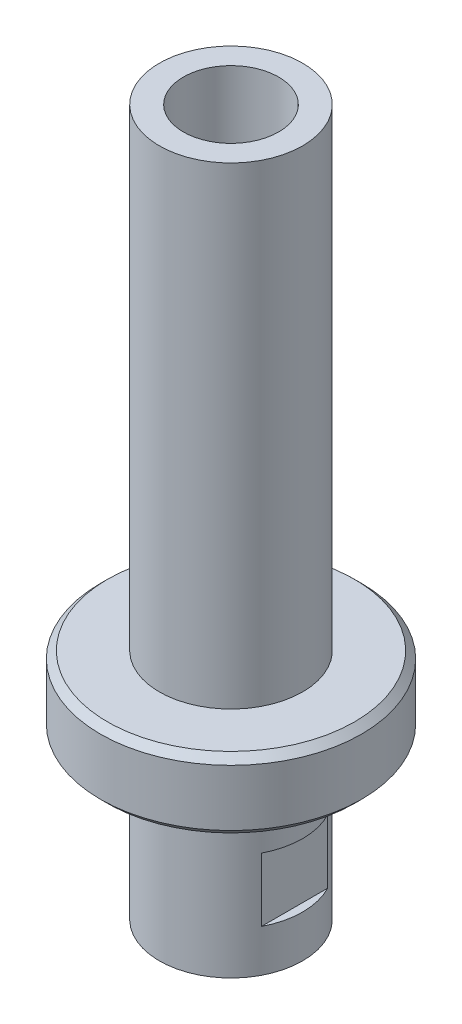
from build123d import *

# Parameters (mm, degrees)
SKETCH2_W               = 3
SKETCH2_H               = 9
CUT_EXTRUDE1_DEPTH      = 19.5
CUT_EXTRUDE1_DEPTH_BACK = 19.5
CHAMFER1_SIZE           = 1


with BuildPart() as part:
    # Sketch1 → Revolve1 (revolve)
    with BuildSketch(Plane.XY):
        Polygon((10.15, 100), (10.15, 33), (18.5, 33), (18.5, 23), (10.15, 23), (10.15, 0), (6.75, 0), (6.75, 100), align=None)
    revolve(axis=Axis((0, -728.004511314, 0), (0, 1, 0)))

    # Sketch2 → Cut-Extrude1 (cut, two sides)
    with BuildSketch(Plane.XY) as cut_extrude1_sk:
        with Locations((10.5, 10.5)):
            Rectangle(SKETCH2_W, SKETCH2_H)
        with Locations((-10.5, 10.5)):
            Rectangle(SKETCH2_W, SKETCH2_H)
    extrude(amount=CUT_EXTRUDE1_DEPTH, mode=Mode.SUBTRACT)
    extrude(cut_extrude1_sk.sketch, amount=-CUT_EXTRUDE1_DEPTH_BACK, mode=Mode.SUBTRACT)

    # Chamfer1
    chamfer1_edges = [part.edges().sort_by_distance(p)[0] for p in [
        (-18.5, 23, 0),
        (-18.5, 33, 0),
    ]]
    chamfer(chamfer1_edges, length=CHAMFER1_SIZE)


solid = part.part
